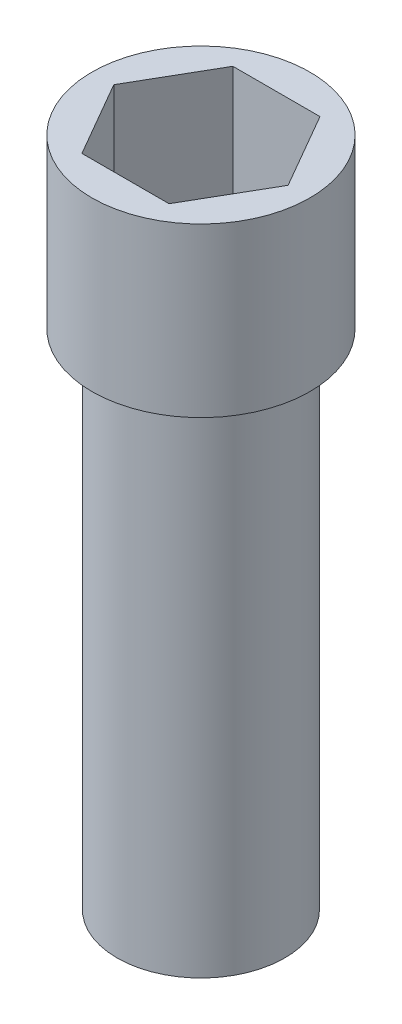
from build123d import *

# Parameters (mm, degrees)
SKETCH1_R           = 5
BOSS_EXTRUDE1_DEPTH = 30
SKETCH2_R           = 6.5
BOSS_EXTRUDE2_DEPTH = 2
SKETCH3_R           = 6.5
BOSS_EXTRUDE3_DEPTH = 8


with BuildPart() as part:
    # Sketch1 → Boss-Extrude1 (new body)
    with BuildSketch(Plane(origin=(0, 0, 0), x_dir=(1, 0, 0), z_dir=(0, 1, 0))):
        Circle(SKETCH1_R)
    extrude(amount=BOSS_EXTRUDE1_DEPTH)

    # Sketch2 → Boss-Extrude2 (add)
    with BuildSketch(Plane(origin=(0, 30, 0), x_dir=(1, 0, 0), z_dir=(0, 1, 0))):
        Circle(SKETCH2_R)
    extrude(amount=BOSS_EXTRUDE2_DEPTH)

    # Sketch3 → Boss-Extrude3 (add)
    with BuildSketch(Plane(origin=(0, 32, 0), x_dir=(1, 0, 0), z_dir=(0, 1, 0))):
        Circle(SKETCH3_R)
        Polygon((5.196152423, 0), (2.598076211, 4.5), (-2.598076211, 4.5), (-5.196152423, 0), (-2.598076211, -4.5), (2.598076211, -4.5), align=None, mode=Mode.SUBTRACT)
    extrude(amount=BOSS_EXTRUDE3_DEPTH)


solid = part.part
